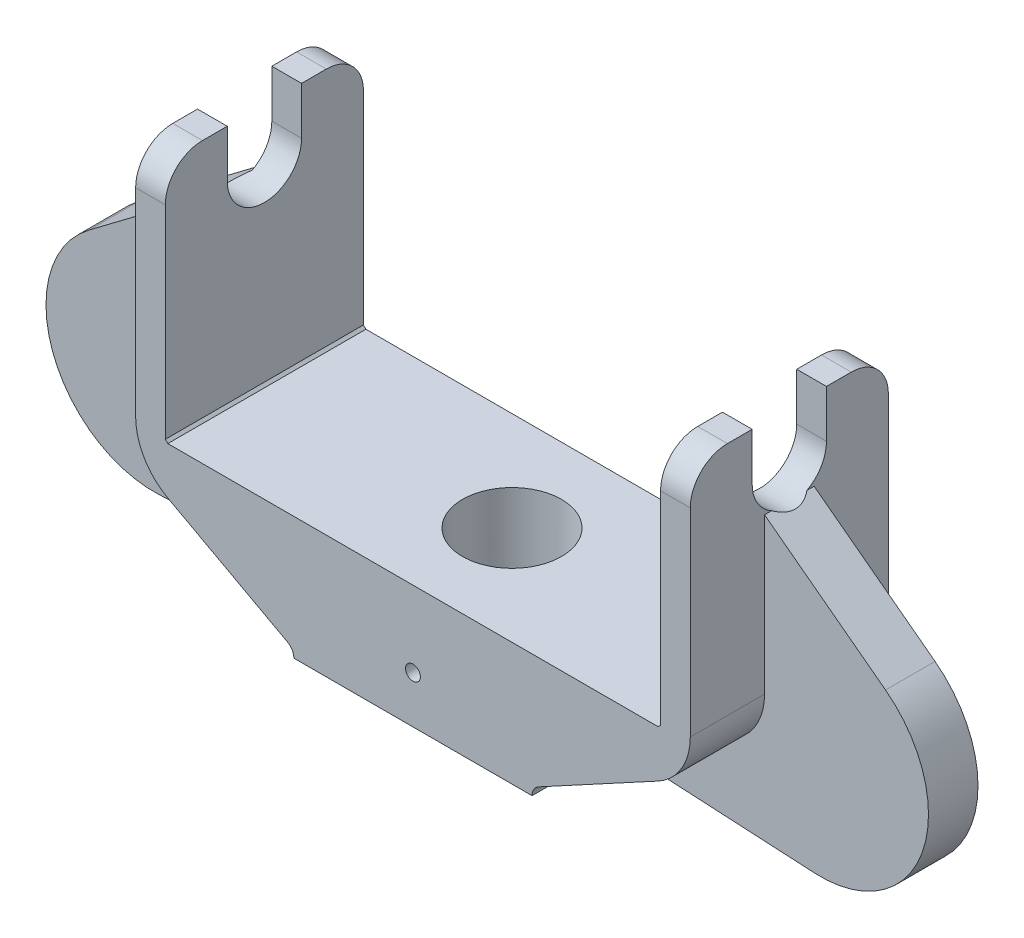
from build123d import *

# Parameters (mm, degrees)
SKETCH1_R               = 0.15
BOSS_EXTRUDE1_DEPTH     = 2
BOSS_EXTRUDE3_DEPTH     = 0.5
CUT_EXTRUDE1_DEPTH      = 9.910022596
CUT_EXTRUDE1_DEPTH_BACK = 9.910022596
CUT_EXTRUDE2_DEPTH      = 4.310022596
CUT_EXTRUDE2_DEPTH_BACK = 15.510022596
SKETCH6_R               = 1
CUT_EXTRUDE3_DEPTH      = 7.43
CUT_EXTRUDE3_DEPTH_BACK = 1.953161862


with BuildPart() as part:
    # Sketch1 → Boss-Extrude1 (new body, symmetric)
    with BuildSketch(Plane.XY):
        with BuildLine():
            Line((-2.405, -0.95), (2.405, -0.95))
            ThreePointArc((2.405, -0.95), (2.440204468, -0.822082529), (2.535903035, -0.73019119))
            Line((2.535903035, -0.73019119), (4.945484826, 0.575370124))
            ThreePointArc((4.945484826, 0.575370124), (5.423977661, 1.034826819), (5.6, 1.674414174))
            Line((5.6, 1.674414174), (5.6, 6.43))
            Line((5.6, 6.43), (5, 6.43))
            Line((5, 6.43), (5, 1.58))
            Line((5, 1.58), (4.95, 1.53))
            Line((4.95, 1.53), (-4.95, 1.53))
            Line((-4.95, 1.53), (-5, 1.58))
            Line((-5, 1.58), (-5, 6.43))
            Line((-5, 6.43), (-5.6, 6.43))
            Line((-5.6, 6.43), (-5.6, 1.674414174))
            ThreePointArc((-5.6, 1.674414174), (-5.423977661, 1.034826819), (-4.945484826, 0.575370124))
            Line((-4.945484826, 0.575370124), (-2.535903035, -0.73019119))
            ThreePointArc((-2.535903035, -0.73019119), (-2.440204468, -0.822082529), (-2.405, -0.95))
        make_face()
        Circle(SKETCH1_R, mode=Mode.SUBTRACT)
    extrude(amount=BOSS_EXTRUDE1_DEPTH, both=True)

    # Sketch2 → Boss-Extrude3 (add, symmetric)
    with BuildSketch(Plane.XY):
        with BuildLine():
            Line((2.535903035, -0.73019119), (4.945484826, 0.575370124))
            ThreePointArc((4.945484826, 0.575370124), (5.423977661, 1.034826819), (5.6, 1.674414174))
            Line((5.6, 1.674414174), (5.6, 4.81))
            Line((5.6, 4.81), (8.042875866, 2.967187611))
            ThreePointArc((8.042875866, 2.967187611), (8.777798155, 0.479164908), (6.61265257, -0.95))
            Line((6.61265257, -0.95), (2.535903035, -0.73019119))
        make_face()
        with BuildLine():
            Line((-2.535903035, -0.73019119), (-4.945484826, 0.575370124))
            ThreePointArc((-4.945484826, 0.575370124), (-5.423977661, 1.034826819), (-5.6, 1.674414174))
            Line((-5.6, 1.674414174), (-5.6, 4.81))
            Line((-5.6, 4.81), (-8.042875866, 2.967187611))
            ThreePointArc((-8.042875866, 2.967187611), (-8.777798155, 0.479164908), (-6.61265257, -0.95))
            Line((-6.61265257, -0.95), (-2.535903035, -0.73019119))
        make_face()
    extrude(amount=BOSS_EXTRUDE3_DEPTH, both=True)

    # Sketch4 → Cut-Extrude1 (cut, two sides)
    with BuildSketch(Plane(origin=(0, 0, 0), x_dir=(0, 0, -1), z_dir=(1, 0, 0))) as cut_extrude1_sk:
        with BuildLine():
            Line((0.75, 5.47), (0.75, 6.97))
            Line((0.75, 6.97), (-0.75, 6.97))
            Line((-0.75, 6.97), (-0.75, 5.47))
            ThreePointArc((-0.75, 5.47), (0, 4.72), (0.75, 5.47))
        make_face()
    extrude(amount=CUT_EXTRUDE1_DEPTH, mode=Mode.SUBTRACT)
    extrude(cut_extrude1_sk.sketch, amount=-CUT_EXTRUDE1_DEPTH_BACK, mode=Mode.SUBTRACT)

    # Sketch5 → Cut-Extrude2 (cut, two sides)
    with BuildSketch(Plane(origin=(5.6, 0, 0), x_dir=(0, 0, -1), z_dir=(1, 0, 0))) as cut_extrude2_sk:
        with BuildLine():
            Line((2, 6.43), (2, 5.68))
            ThreePointArc((2, 5.68), (1.780330086, 6.210330086), (1.25, 6.43))
            Line((1.25, 6.43), (2, 6.43))
        make_face()
        with BuildLine():
            Line((-2, 6.43), (-2, 5.68))
            ThreePointArc((-2, 5.68), (-1.780330086, 6.210330086), (-1.25, 6.43))
            Line((-1.25, 6.43), (-2, 6.43))
        make_face()
    extrude(amount=CUT_EXTRUDE2_DEPTH, mode=Mode.SUBTRACT)
    extrude(cut_extrude2_sk.sketch, amount=-CUT_EXTRUDE2_DEPTH_BACK, mode=Mode.SUBTRACT)

    # Sketch6 → Cut-Extrude3 (cut, two sides)
    with BuildSketch(Plane(origin=(0, 0, 0), x_dir=(1, 0, 0), z_dir=(0, 1, 0))) as cut_extrude3_sk:
        Circle(SKETCH6_R)
    extrude(amount=CUT_EXTRUDE3_DEPTH, mode=Mode.SUBTRACT)
    extrude(cut_extrude3_sk.sketch, amount=-CUT_EXTRUDE3_DEPTH_BACK, mode=Mode.SUBTRACT)


solid = part.part
